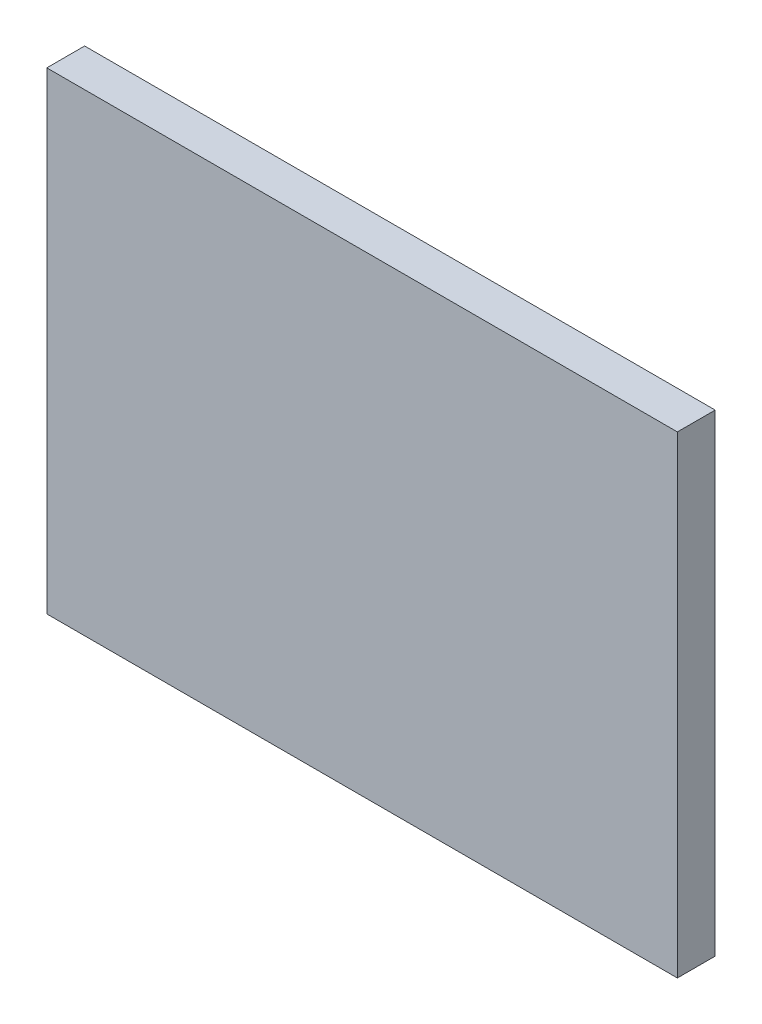
from build123d import *

# Parameters (mm, degrees)
ESBO_O1_W                = 20
ESBO_O1_H                = 15
RESSALTO_EXTRUS_O1_DEPTH = 1.2


with BuildPart() as part:
    # Esboço1 → Ressalto-extrusão1 (new body)
    with BuildSketch(Plane.XY):
        with Locations((-10, 7.5)):
            Rectangle(ESBO_O1_W, ESBO_O1_H)
    extrude(amount=RESSALTO_EXTRUS_O1_DEPTH)


solid = part.part
